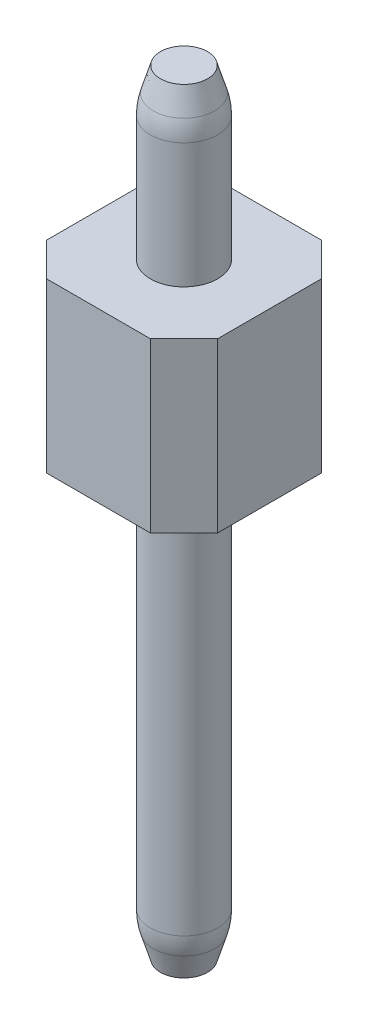
from build123d import *

# Parameters (mm, degrees)
SKETCH1_R               = 0.5
BOSS_EXTRUDE1_DEPTH     = 11.5
BOSS_EXTRUDE1_2_DEPTH   = 11.5
BOSS_EXTRUDE1_3_DEPTH   = 11.5
BOSS_EXTRUDE1_4_DEPTH   = 11.5
BOSS_EXTRUDE1_5_DEPTH   = 11.5
BOSS_EXTRUDE1_6_DEPTH   = 11.5
BOSS_EXTRUDE1_7_DEPTH   = 11.5
BOSS_EXTRUDE1_8_DEPTH   = 11.5
BOSS_EXTRUDE1_9_DEPTH   = 11.5
BOSS_EXTRUDE1_10_DEPTH  = 11.5
BOSS_EXTRUDE1_11_DEPTH  = 11.5
BOSS_EXTRUDE1_12_DEPTH  = 11.5
BOSS_EXTRUDE1_13_DEPTH  = 11.5
BOSS_EXTRUDE1_14_DEPTH  = 11.5
BOSS_EXTRUDE1_15_DEPTH  = 11.5
BOSS_EXTRUDE1_16_DEPTH  = 11.5
BOSS_EXTRUDE2_DEPTH     = 2.5
CHAMFER1_SIZE           = 0.5
CHAMFER1_SIZE2          = 0.15
CHAMFER1_PART_2_SIZE    = 0.5
CHAMFER1_PART_2_SIZE2   = 0.15
CHAMFER1_PART_3_SIZE    = 0.5
CHAMFER1_PART_3_SIZE2   = 0.15
CHAMFER1_PART_4_SIZE    = 0.5
CHAMFER1_PART_4_SIZE2   = 0.15
CHAMFER1_PART_5_SIZE    = 0.5
CHAMFER1_PART_5_SIZE2   = 0.15
CHAMFER1_PART_6_SIZE    = 0.5
CHAMFER1_PART_6_SIZE2   = 0.15
CHAMFER1_PART_7_SIZE    = 0.5
CHAMFER1_PART_7_SIZE2   = 0.15
CHAMFER1_PART_8_SIZE    = 0.5
CHAMFER1_PART_8_SIZE2   = 0.15
CHAMFER1_PART_9_SIZE    = 0.5
CHAMFER1_PART_9_SIZE2   = 0.15
CHAMFER1_PART_10_SIZE   = 0.5
CHAMFER1_PART_10_SIZE2  = 0.15
CHAMFER1_PART_11_SIZE   = 0.5
CHAMFER1_PART_11_SIZE2  = 0.15
CHAMFER1_PART_12_SIZE   = 0.5
CHAMFER1_PART_12_SIZE2  = 0.15
CHAMFER1_PART_13_SIZE   = 0.5
CHAMFER1_PART_13_SIZE2  = 0.15
CHAMFER1_PART_14_SIZE   = 0.5
CHAMFER1_PART_14_SIZE2  = 0.15
CHAMFER1_PART_15_SIZE   = 0.5
CHAMFER1_PART_15_SIZE2  = 0.15
CHAMFER1_PART_16_SIZE   = 0.5
CHAMFER1_PART_16_SIZE2  = 0.15
FILLET1_R               = 1
CHAMFER2_SIZE           = 0.15
CHAMFER2_SIZE2          = 0.5
CHAMFER2_PART_2_SIZE    = 0.15
CHAMFER2_PART_2_SIZE2   = 0.5
CHAMFER2_PART_3_SIZE    = 0.15
CHAMFER2_PART_3_SIZE2   = 0.5
CHAMFER2_PART_4_SIZE    = 0.15
CHAMFER2_PART_4_SIZE2   = 0.5
CHAMFER2_PART_5_SIZE    = 0.15
CHAMFER2_PART_5_SIZE2   = 0.5
CHAMFER2_PART_6_SIZE    = 0.15
CHAMFER2_PART_6_SIZE2   = 0.5
CHAMFER2_PART_7_SIZE    = 0.15
CHAMFER2_PART_7_SIZE2   = 0.5
CHAMFER2_PART_8_SIZE    = 0.15
CHAMFER2_PART_8_SIZE2   = 0.5
CHAMFER2_PART_9_SIZE    = 0.15
CHAMFER2_PART_9_SIZE2   = 0.5
CHAMFER2_PART_10_SIZE   = 0.15
CHAMFER2_PART_10_SIZE2  = 0.5
CHAMFER2_PART_11_SIZE   = 0.15
CHAMFER2_PART_11_SIZE2  = 0.5
CHAMFER2_PART_12_SIZE   = 0.15
CHAMFER2_PART_12_SIZE2  = 0.5
CHAMFER2_PART_13_SIZE   = 0.15
CHAMFER2_PART_13_SIZE2  = 0.5
CHAMFER2_PART_14_SIZE   = 0.15
CHAMFER2_PART_14_SIZE2  = 0.5
CHAMFER2_PART_15_SIZE   = 0.15
CHAMFER2_PART_15_SIZE2  = 0.5
CHAMFER2_PART_16_SIZE   = 0.15
CHAMFER2_PART_16_SIZE2  = 0.5
FILLET2_R               = 1
SKETCH3_W               = 38.1
SKETCH3_H               = 11.5
CUT_EXTRUDE1_DEPTH      = 1
CUT_EXTRUDE1_DEPTH_BACK = 3.54


with BuildPart() as part:
    # Sketch1 → Boss-Extrude1 (new body)
    with BuildSketch(Plane(origin=(0, 0, 0), x_dir=(1, 0, 0), z_dir=(0, 1, 0))):
        Circle(SKETCH1_R)
    extrude(amount=BOSS_EXTRUDE1_DEPTH)



with BuildPart() as body_2:
    # Sketch1 → Boss-Extrude1 2 (new body)
    with BuildSketch(Plane(origin=(0, 0, 0), x_dir=(1, 0, 0), z_dir=(0, 1, 0))):
        with Locations((2.54, 0)):
            Circle(SKETCH1_R)
    extrude(amount=BOSS_EXTRUDE1_2_DEPTH)


with BuildPart() as body_3:
    # Sketch1 → Boss-Extrude1 3 (new body)
    with BuildSketch(Plane(origin=(0, 0, 0), x_dir=(1, 0, 0), z_dir=(0, 1, 0))):
        with Locations((5.08, 0)):
            Circle(SKETCH1_R)
    extrude(amount=BOSS_EXTRUDE1_3_DEPTH)


with BuildPart() as body_4:
    # Sketch1 → Boss-Extrude1 4 (new body)
    with BuildSketch(Plane(origin=(0, 0, 0), x_dir=(1, 0, 0), z_dir=(0, 1, 0))):
        with Locations((7.62, 0)):
            Circle(SKETCH1_R)
    extrude(amount=BOSS_EXTRUDE1_4_DEPTH)


with BuildPart() as body_5:
    # Sketch1 → Boss-Extrude1 5 (new body)
    with BuildSketch(Plane(origin=(0, 0, 0), x_dir=(1, 0, 0), z_dir=(0, 1, 0))):
        with Locations((10.16, 0)):
            Circle(SKETCH1_R)
    extrude(amount=BOSS_EXTRUDE1_5_DEPTH)


with BuildPart() as body_6:
    # Sketch1 → Boss-Extrude1 6 (new body)
    with BuildSketch(Plane(origin=(0, 0, 0), x_dir=(1, 0, 0), z_dir=(0, 1, 0))):
        with Locations((12.7, 0)):
            Circle(SKETCH1_R)
    extrude(amount=BOSS_EXTRUDE1_6_DEPTH)


with BuildPart() as body_7:
    # Sketch1 → Boss-Extrude1 7 (new body)
    with BuildSketch(Plane(origin=(0, 0, 0), x_dir=(1, 0, 0), z_dir=(0, 1, 0))):
        with Locations((15.24, 0)):
            Circle(SKETCH1_R)
    extrude(amount=BOSS_EXTRUDE1_7_DEPTH)


with BuildPart() as body_8:
    # Sketch1 → Boss-Extrude1 8 (new body)
    with BuildSketch(Plane(origin=(0, 0, 0), x_dir=(1, 0, 0), z_dir=(0, 1, 0))):
        with Locations((17.78, 0)):
            Circle(SKETCH1_R)
    extrude(amount=BOSS_EXTRUDE1_8_DEPTH)


with BuildPart() as body_9:
    # Sketch1 → Boss-Extrude1 9 (new body)
    with BuildSketch(Plane(origin=(0, 0, 0), x_dir=(1, 0, 0), z_dir=(0, 1, 0))):
        with Locations((20.32, 0)):
            Circle(SKETCH1_R)
    extrude(amount=BOSS_EXTRUDE1_9_DEPTH)


with BuildPart() as body_10:
    # Sketch1 → Boss-Extrude1 10 (new body)
    with BuildSketch(Plane(origin=(0, 0, 0), x_dir=(1, 0, 0), z_dir=(0, 1, 0))):
        with Locations((22.86, 0)):
            Circle(SKETCH1_R)
    extrude(amount=BOSS_EXTRUDE1_10_DEPTH)


with BuildPart() as body_11:
    # Sketch1 → Boss-Extrude1 11 (new body)
    with BuildSketch(Plane(origin=(0, 0, 0), x_dir=(1, 0, 0), z_dir=(0, 1, 0))):
        with Locations((25.4, 0)):
            Circle(SKETCH1_R)
    extrude(amount=BOSS_EXTRUDE1_11_DEPTH)


with BuildPart() as body_12:
    # Sketch1 → Boss-Extrude1 12 (new body)
    with BuildSketch(Plane(origin=(0, 0, 0), x_dir=(1, 0, 0), z_dir=(0, 1, 0))):
        with Locations((27.94, 0)):
            Circle(SKETCH1_R)
    extrude(amount=BOSS_EXTRUDE1_12_DEPTH)


with BuildPart() as body_13:
    # Sketch1 → Boss-Extrude1 13 (new body)
    with BuildSketch(Plane(origin=(0, 0, 0), x_dir=(1, 0, 0), z_dir=(0, 1, 0))):
        with Locations((30.48, 0)):
            Circle(SKETCH1_R)
    extrude(amount=BOSS_EXTRUDE1_13_DEPTH)


with BuildPart() as body_14:
    # Sketch1 → Boss-Extrude1 14 (new body)
    with BuildSketch(Plane(origin=(0, 0, 0), x_dir=(1, 0, 0), z_dir=(0, 1, 0))):
        with Locations((33.02, 0)):
            Circle(SKETCH1_R)
    extrude(amount=BOSS_EXTRUDE1_14_DEPTH)


with BuildPart() as body_15:
    # Sketch1 → Boss-Extrude1 15 (new body)
    with BuildSketch(Plane(origin=(0, 0, 0), x_dir=(1, 0, 0), z_dir=(0, 1, 0))):
        with Locations((35.56, 0)):
            Circle(SKETCH1_R)
    extrude(amount=BOSS_EXTRUDE1_15_DEPTH)


with BuildPart() as body_16:
    # Sketch1 → Boss-Extrude1 16 (new body)
    with BuildSketch(Plane(origin=(0, 0, 0), x_dir=(1, 0, 0), z_dir=(0, 1, 0))):
        with Locations((38.1, 0)):
            Circle(SKETCH1_R)
    extrude(amount=BOSS_EXTRUDE1_16_DEPTH)


with BuildPart() as part_1:
    add(part.part)

    add(body_2.part)  # Boss-Extrude2 merges body 2

    add(body_3.part)  # Boss-Extrude2 merges body 3

    add(body_4.part)  # Boss-Extrude2 merges body 4

    add(body_5.part)  # Boss-Extrude2 merges body 5

    add(body_6.part)  # Boss-Extrude2 merges body 6

    add(body_7.part)  # Boss-Extrude2 merges body 7

    add(body_8.part)  # Boss-Extrude2 merges body 8

    add(body_9.part)  # Boss-Extrude2 merges body 9

    add(body_10.part)  # Boss-Extrude2 merges body 10

    add(body_11.part)  # Boss-Extrude2 merges body 11

    add(body_12.part)  # Boss-Extrude2 merges body 12

    add(body_13.part)  # Boss-Extrude2 merges body 13

    add(body_14.part)  # Boss-Extrude2 merges body 14

    add(body_15.part)  # Boss-Extrude2 merges body 15

    add(body_16.part)  # Boss-Extrude2 merges body 16
    # Sketch2 → Boss-Extrude2 (add)
    with BuildSketch(Plane(origin=(0, 6.5, 0), x_dir=(1, 0, 0), z_dir=(0, 1, 0))):
        Polygon((-1.27, 0.77), (-0.77, 1.27), (0.77, 1.27), (1.27, 0.77), (1.77, 1.27), (3.31, 1.27), (3.81, 0.77), (4.31, 1.27), (5.85, 1.27), (6.35, 0.77), (6.85, 1.27), (8.39, 1.27), (8.89, 0.77), (9.39, 1.27), (10.93, 1.27), (11.43, 0.77), (11.93, 1.27), (13.47, 1.27), (13.97, 0.77), (14.47, 1.27), (16.01, 1.27), (16.51, 0.77), (17.01, 1.27), (18.55, 1.27), (19.05, 0.77), (19.55, 1.27), (21.09, 1.27), (21.59, 0.77), (22.09, 1.27), (23.63, 1.27), (24.13, 0.77), (24.63, 1.27), (26.17, 1.27), (26.67, 0.77), (27.17, 1.27), (28.71, 1.27), (29.21, 0.77), (29.71, 1.27), (31.25, 1.27), (31.75, 0.77), (32.25, 1.27), (33.79, 1.27), (34.29, 0.77), (34.79, 1.27), (36.33, 1.27), (36.83, 0.77), (37.33, 1.27), (38.87, 1.27), (39.37, 0.77), (39.37, -0.77), (38.87, -1.27), (37.33, -1.27), (36.83, -0.77), (36.33, -1.27), (34.79, -1.27), (34.29, -0.77), (33.79, -1.27), (32.25, -1.27), (31.75, -0.77), (31.25, -1.27), (29.71, -1.27), (29.21, -0.77), (28.71, -1.27), (27.17, -1.27), (26.67, -0.77), (26.17, -1.27), (24.63, -1.27), (24.13, -0.77), (23.63, -1.27), (22.09, -1.27), (21.59, -0.77), (21.09, -1.27), (19.55, -1.27), (19.05, -0.77), (18.55, -1.27), (17.01, -1.27), (16.51, -0.77), (16.01, -1.27), (14.47, -1.27), (13.97, -0.77), (13.47, -1.27), (11.93, -1.27), (11.43, -0.77), (10.93, -1.27), (9.39, -1.27), (8.89, -0.77), (8.39, -1.27), (6.85, -1.27), (6.35, -0.77), (5.85, -1.27), (4.31, -1.27), (3.81, -0.77), (3.31, -1.27), (1.77, -1.27), (1.27, -0.77), (0.77, -1.27), (-0.77, -1.27), (-1.27, -0.77), align=None)
    extrude(amount=BOSS_EXTRUDE2_DEPTH)

    # Chamfer1
    chamfer1_edges = [part_1.edges().sort_by_distance(p)[0] for p in [
        (2.04, 11.5, 0),
    ]]
    chamfer1_side = [part_1.faces().sort_by_distance(p)[0] for p in [
        (2.04, 10.25, 0),
    ]]
    chamfer(chamfer1_edges, length=CHAMFER1_SIZE, length2=CHAMFER1_SIZE2, reference=chamfer1_side[0])

    # Chamfer1 part 2
    chamfer1_part_2_edges = [part_1.edges().sort_by_distance(p)[0] for p in [
        (4.58, 11.5, 0),
    ]]
    chamfer1_part_2_side = [part_1.faces().sort_by_distance(p)[0] for p in [
        (4.58, 10.25, 0),
    ]]
    chamfer(chamfer1_part_2_edges, length=CHAMFER1_PART_2_SIZE, length2=CHAMFER1_PART_2_SIZE2, reference=chamfer1_part_2_side[0])

    # Chamfer1 part 3
    chamfer1_part_3_edges = [part_1.edges().sort_by_distance(p)[0] for p in [
        (7.12, 11.5, 0),
    ]]
    chamfer1_part_3_side = [part_1.faces().sort_by_distance(p)[0] for p in [
        (7.12, 10.25, 0),
    ]]
    chamfer(chamfer1_part_3_edges, length=CHAMFER1_PART_3_SIZE, length2=CHAMFER1_PART_3_SIZE2, reference=chamfer1_part_3_side[0])

    # Chamfer1 part 4
    chamfer1_part_4_edges = [part_1.edges().sort_by_distance(p)[0] for p in [
        (9.66, 11.5, 0),
    ]]
    chamfer1_part_4_side = [part_1.faces().sort_by_distance(p)[0] for p in [
        (9.66, 10.25, 0),
    ]]
    chamfer(chamfer1_part_4_edges, length=CHAMFER1_PART_4_SIZE, length2=CHAMFER1_PART_4_SIZE2, reference=chamfer1_part_4_side[0])

    # Chamfer1 part 5
    chamfer1_part_5_edges = [part_1.edges().sort_by_distance(p)[0] for p in [
        (12.2, 11.5, 0),
    ]]
    chamfer1_part_5_side = [part_1.faces().sort_by_distance(p)[0] for p in [
        (12.2, 10.25, 0),
    ]]
    chamfer(chamfer1_part_5_edges, length=CHAMFER1_PART_5_SIZE, length2=CHAMFER1_PART_5_SIZE2, reference=chamfer1_part_5_side[0])

    # Chamfer1 part 6
    chamfer1_part_6_edges = [part_1.edges().sort_by_distance(p)[0] for p in [
        (14.74, 11.5, 0),
    ]]
    chamfer1_part_6_side = [part_1.faces().sort_by_distance(p)[0] for p in [
        (14.74, 10.25, 0),
    ]]
    chamfer(chamfer1_part_6_edges, length=CHAMFER1_PART_6_SIZE, length2=CHAMFER1_PART_6_SIZE2, reference=chamfer1_part_6_side[0])

    # Chamfer1 part 7
    chamfer1_part_7_edges = [part_1.edges().sort_by_distance(p)[0] for p in [
        (17.28, 11.5, 0),
    ]]
    chamfer1_part_7_side = [part_1.faces().sort_by_distance(p)[0] for p in [
        (17.28, 10.25, 0),
    ]]
    chamfer(chamfer1_part_7_edges, length=CHAMFER1_PART_7_SIZE, length2=CHAMFER1_PART_7_SIZE2, reference=chamfer1_part_7_side[0])

    # Chamfer1 part 8
    chamfer1_part_8_edges = [part_1.edges().sort_by_distance(p)[0] for p in [
        (19.82, 11.5, 0),
    ]]
    chamfer1_part_8_side = [part_1.faces().sort_by_distance(p)[0] for p in [
        (19.82, 10.25, 0),
    ]]
    chamfer(chamfer1_part_8_edges, length=CHAMFER1_PART_8_SIZE, length2=CHAMFER1_PART_8_SIZE2, reference=chamfer1_part_8_side[0])

    # Chamfer1 part 9
    chamfer1_part_9_edges = [part_1.edges().sort_by_distance(p)[0] for p in [
        (22.36, 11.5, 0),
    ]]
    chamfer1_part_9_side = [part_1.faces().sort_by_distance(p)[0] for p in [
        (22.36, 10.25, 0),
    ]]
    chamfer(chamfer1_part_9_edges, length=CHAMFER1_PART_9_SIZE, length2=CHAMFER1_PART_9_SIZE2, reference=chamfer1_part_9_side[0])

    # Chamfer1 part 10
    chamfer1_part_10_edges = [part_1.edges().sort_by_distance(p)[0] for p in [
        (24.9, 11.5, 0),
    ]]
    chamfer1_part_10_side = [part_1.faces().sort_by_distance(p)[0] for p in [
        (24.9, 10.25, 0),
    ]]
    chamfer(chamfer1_part_10_edges, length=CHAMFER1_PART_10_SIZE, length2=CHAMFER1_PART_10_SIZE2, reference=chamfer1_part_10_side[0])

    # Chamfer1 part 11
    chamfer1_part_11_edges = [part_1.edges().sort_by_distance(p)[0] for p in [
        (27.44, 11.5, 0),
    ]]
    chamfer1_part_11_side = [part_1.faces().sort_by_distance(p)[0] for p in [
        (27.44, 10.25, 0),
    ]]
    chamfer(chamfer1_part_11_edges, length=CHAMFER1_PART_11_SIZE, length2=CHAMFER1_PART_11_SIZE2, reference=chamfer1_part_11_side[0])

    # Chamfer1 part 12
    chamfer1_part_12_edges = [part_1.edges().sort_by_distance(p)[0] for p in [
        (29.98, 11.5, 0),
    ]]
    chamfer1_part_12_side = [part_1.faces().sort_by_distance(p)[0] for p in [
        (29.98, 10.25, 0),
    ]]
    chamfer(chamfer1_part_12_edges, length=CHAMFER1_PART_12_SIZE, length2=CHAMFER1_PART_12_SIZE2, reference=chamfer1_part_12_side[0])

    # Chamfer1 part 13
    chamfer1_part_13_edges = [part_1.edges().sort_by_distance(p)[0] for p in [
        (32.52, 11.5, 0),
    ]]
    chamfer1_part_13_side = [part_1.faces().sort_by_distance(p)[0] for p in [
        (32.52, 10.25, 0),
    ]]
    chamfer(chamfer1_part_13_edges, length=CHAMFER1_PART_13_SIZE, length2=CHAMFER1_PART_13_SIZE2, reference=chamfer1_part_13_side[0])

    # Chamfer1 part 14
    chamfer1_part_14_edges = [part_1.edges().sort_by_distance(p)[0] for p in [
        (35.06, 11.5, 0),
    ]]
    chamfer1_part_14_side = [part_1.faces().sort_by_distance(p)[0] for p in [
        (35.06, 10.25, 0),
    ]]
    chamfer(chamfer1_part_14_edges, length=CHAMFER1_PART_14_SIZE, length2=CHAMFER1_PART_14_SIZE2, reference=chamfer1_part_14_side[0])

    # Chamfer1 part 15
    chamfer1_part_15_edges = [part_1.edges().sort_by_distance(p)[0] for p in [
        (37.6, 11.5, 0),
    ]]
    chamfer1_part_15_side = [part_1.faces().sort_by_distance(p)[0] for p in [
        (37.6, 10.25, 0),
    ]]
    chamfer(chamfer1_part_15_edges, length=CHAMFER1_PART_15_SIZE, length2=CHAMFER1_PART_15_SIZE2, reference=chamfer1_part_15_side[0])

    # Chamfer1 part 16
    chamfer1_part_16_edges = [part_1.edges().sort_by_distance(p)[0] for p in [
        (-0.5, 11.5, 0),
    ]]
    chamfer1_part_16_side = [part_1.faces().sort_by_distance(p)[0] for p in [
        (-0.5, 10.25, 0),
    ]]
    chamfer(chamfer1_part_16_edges, length=CHAMFER1_PART_16_SIZE, length2=CHAMFER1_PART_16_SIZE2, reference=chamfer1_part_16_side[0])

    # Fillet1
    fillet1_edges = [part_1.edges().sort_by_distance(p)[0] for p in [
        (37.6, 11, 0),
        (35.06, 11, 0),
        (32.52, 11, 0),
        (29.98, 11, 0),
        (27.44, 11, 0),
        (24.9, 11, 0),
        (22.36, 11, 0),
        (19.82, 11, 0),
        (17.28, 11, 0),
        (14.74, 11, 0),
        (12.2, 11, 0),
        (9.66, 11, 0),
        (7.12, 11, 0),
        (4.58, 11, 0),
        (2.04, 11, 0),
        (-0.5, 11, 0),
    ]]
    fillet(fillet1_edges, radius=FILLET1_R)

    # Chamfer2
    chamfer2_edges = [part_1.edges().sort_by_distance(p)[0] for p in [
        (-0.5, 0, 0),
    ]]
    chamfer2_side = [part_1.faces().sort_by_distance(p)[0] for p in [
        (0, 0, 0),
    ]]
    chamfer(chamfer2_edges, length=CHAMFER2_SIZE, length2=CHAMFER2_SIZE2, reference=chamfer2_side[0])

    # Chamfer2 part 2
    chamfer2_part_2_edges = [part_1.edges().sort_by_distance(p)[0] for p in [
        (2.04, 0, 0),
    ]]
    chamfer2_part_2_side = [part_1.faces().sort_by_distance(p)[0] for p in [
        (2.54, 0, 0),
    ]]
    chamfer(chamfer2_part_2_edges, length=CHAMFER2_PART_2_SIZE, length2=CHAMFER2_PART_2_SIZE2, reference=chamfer2_part_2_side[0])

    # Chamfer2 part 3
    chamfer2_part_3_edges = [part_1.edges().sort_by_distance(p)[0] for p in [
        (4.58, 0, 0),
    ]]
    chamfer2_part_3_side = [part_1.faces().sort_by_distance(p)[0] for p in [
        (5.08, 0, 0),
    ]]
    chamfer(chamfer2_part_3_edges, length=CHAMFER2_PART_3_SIZE, length2=CHAMFER2_PART_3_SIZE2, reference=chamfer2_part_3_side[0])

    # Chamfer2 part 4
    chamfer2_part_4_edges = [part_1.edges().sort_by_distance(p)[0] for p in [
        (7.12, 0, 0),
    ]]
    chamfer2_part_4_side = [part_1.faces().sort_by_distance(p)[0] for p in [
        (7.62, 0, 0),
    ]]
    chamfer(chamfer2_part_4_edges, length=CHAMFER2_PART_4_SIZE, length2=CHAMFER2_PART_4_SIZE2, reference=chamfer2_part_4_side[0])

    # Chamfer2 part 5
    chamfer2_part_5_edges = [part_1.edges().sort_by_distance(p)[0] for p in [
        (9.66, 0, 0),
    ]]
    chamfer2_part_5_side = [part_1.faces().sort_by_distance(p)[0] for p in [
        (10.16, 0, 0),
    ]]
    chamfer(chamfer2_part_5_edges, length=CHAMFER2_PART_5_SIZE, length2=CHAMFER2_PART_5_SIZE2, reference=chamfer2_part_5_side[0])

    # Chamfer2 part 6
    chamfer2_part_6_edges = [part_1.edges().sort_by_distance(p)[0] for p in [
        (12.2, 0, 0),
    ]]
    chamfer2_part_6_side = [part_1.faces().sort_by_distance(p)[0] for p in [
        (12.7, 0, 0),
    ]]
    chamfer(chamfer2_part_6_edges, length=CHAMFER2_PART_6_SIZE, length2=CHAMFER2_PART_6_SIZE2, reference=chamfer2_part_6_side[0])

    # Chamfer2 part 7
    chamfer2_part_7_edges = [part_1.edges().sort_by_distance(p)[0] for p in [
        (14.74, 0, 0),
    ]]
    chamfer2_part_7_side = [part_1.faces().sort_by_distance(p)[0] for p in [
        (15.24, 0, 0),
    ]]
    chamfer(chamfer2_part_7_edges, length=CHAMFER2_PART_7_SIZE, length2=CHAMFER2_PART_7_SIZE2, reference=chamfer2_part_7_side[0])

    # Chamfer2 part 8
    chamfer2_part_8_edges = [part_1.edges().sort_by_distance(p)[0] for p in [
        (17.28, 0, 0),
    ]]
    chamfer2_part_8_side = [part_1.faces().sort_by_distance(p)[0] for p in [
        (17.78, 0, 0),
    ]]
    chamfer(chamfer2_part_8_edges, length=CHAMFER2_PART_8_SIZE, length2=CHAMFER2_PART_8_SIZE2, reference=chamfer2_part_8_side[0])

    # Chamfer2 part 9
    chamfer2_part_9_edges = [part_1.edges().sort_by_distance(p)[0] for p in [
        (19.82, 0, 0),
    ]]
    chamfer2_part_9_side = [part_1.faces().sort_by_distance(p)[0] for p in [
        (20.32, 0, 0),
    ]]
    chamfer(chamfer2_part_9_edges, length=CHAMFER2_PART_9_SIZE, length2=CHAMFER2_PART_9_SIZE2, reference=chamfer2_part_9_side[0])

    # Chamfer2 part 10
    chamfer2_part_10_edges = [part_1.edges().sort_by_distance(p)[0] for p in [
        (22.36, 0, 0),
    ]]
    chamfer2_part_10_side = [part_1.faces().sort_by_distance(p)[0] for p in [
        (22.86, 0, 0),
    ]]
    chamfer(chamfer2_part_10_edges, length=CHAMFER2_PART_10_SIZE, length2=CHAMFER2_PART_10_SIZE2, reference=chamfer2_part_10_side[0])

    # Chamfer2 part 11
    chamfer2_part_11_edges = [part_1.edges().sort_by_distance(p)[0] for p in [
        (24.9, 0, 0),
    ]]
    chamfer2_part_11_side = [part_1.faces().sort_by_distance(p)[0] for p in [
        (25.4, 0, 0),
    ]]
    chamfer(chamfer2_part_11_edges, length=CHAMFER2_PART_11_SIZE, length2=CHAMFER2_PART_11_SIZE2, reference=chamfer2_part_11_side[0])

    # Chamfer2 part 12
    chamfer2_part_12_edges = [part_1.edges().sort_by_distance(p)[0] for p in [
        (27.44, 0, 0),
    ]]
    chamfer2_part_12_side = [part_1.faces().sort_by_distance(p)[0] for p in [
        (27.94, 0, 0),
    ]]
    chamfer(chamfer2_part_12_edges, length=CHAMFER2_PART_12_SIZE, length2=CHAMFER2_PART_12_SIZE2, reference=chamfer2_part_12_side[0])

    # Chamfer2 part 13
    chamfer2_part_13_edges = [part_1.edges().sort_by_distance(p)[0] for p in [
        (29.98, 0, 0),
    ]]
    chamfer2_part_13_side = [part_1.faces().sort_by_distance(p)[0] for p in [
        (30.48, 0, 0),
    ]]
    chamfer(chamfer2_part_13_edges, length=CHAMFER2_PART_13_SIZE, length2=CHAMFER2_PART_13_SIZE2, reference=chamfer2_part_13_side[0])

    # Chamfer2 part 14
    chamfer2_part_14_edges = [part_1.edges().sort_by_distance(p)[0] for p in [
        (32.52, 0, 0),
    ]]
    chamfer2_part_14_side = [part_1.faces().sort_by_distance(p)[0] for p in [
        (33.02, 0, 0),
    ]]
    chamfer(chamfer2_part_14_edges, length=CHAMFER2_PART_14_SIZE, length2=CHAMFER2_PART_14_SIZE2, reference=chamfer2_part_14_side[0])

    # Chamfer2 part 15
    chamfer2_part_15_edges = [part_1.edges().sort_by_distance(p)[0] for p in [
        (35.06, 0, 0),
    ]]
    chamfer2_part_15_side = [part_1.faces().sort_by_distance(p)[0] for p in [
        (35.56, 0, 0),
    ]]
    chamfer(chamfer2_part_15_edges, length=CHAMFER2_PART_15_SIZE, length2=CHAMFER2_PART_15_SIZE2, reference=chamfer2_part_15_side[0])

    # Chamfer2 part 16
    chamfer2_part_16_edges = [part_1.edges().sort_by_distance(p)[0] for p in [
        (37.6, 0, 0),
    ]]
    chamfer2_part_16_side = [part_1.faces().sort_by_distance(p)[0] for p in [
        (38.1, 0, 0),
    ]]
    chamfer(chamfer2_part_16_edges, length=CHAMFER2_PART_16_SIZE, length2=CHAMFER2_PART_16_SIZE2, reference=chamfer2_part_16_side[0])

    # Fillet2
    fillet2_edges = [part_1.edges().sort_by_distance(p)[0] for p in [
        (9.66, 0.5, 0),
        (17.28, 0.5, 0),
        (22.36, 0.5, 0),
        (27.44, 0.5, 0),
        (29.98, 0.5, 0),
        (-0.5, 0.5, 0),
        (2.04, 0.5, 0),
        (4.58, 0.5, 0),
        (7.12, 0.5, 0),
        (12.2, 0.5, 0),
        (14.74, 0.5, 0),
        (19.82, 0.5, 0),
        (24.9, 0.5, 0),
        (32.52, 0.5, 0),
        (35.06, 0.5, 0),
        (37.6, 0.5, 0),
    ]]
    fillet(fillet2_edges, radius=FILLET2_R)

    # Sketch3 → Cut-Extrude1 (cut, two sides)
    with BuildSketch(Plane.XY.offset(1.27)) as cut_extrude1_sk:
        with Locations((20.32, 5.75)):
            Rectangle(SKETCH3_W, SKETCH3_H)
    extrude(amount=CUT_EXTRUDE1_DEPTH, mode=Mode.SUBTRACT)
    extrude(cut_extrude1_sk.sketch, amount=-CUT_EXTRUDE1_DEPTH_BACK, mode=Mode.SUBTRACT)


solid = part_1.part
